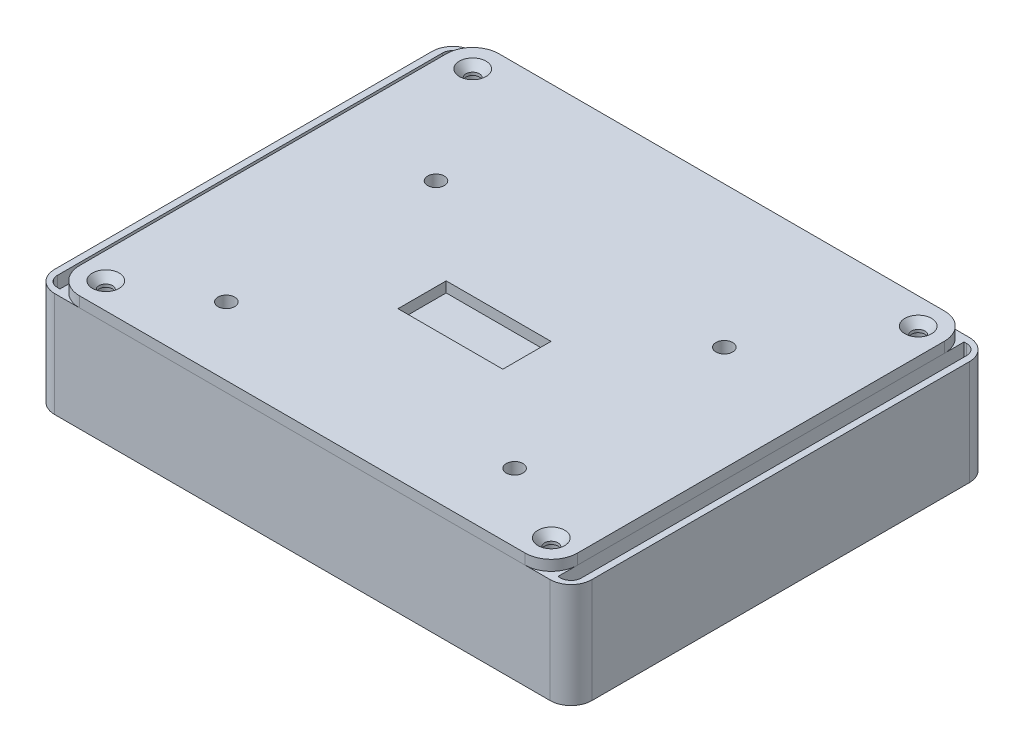
from build123d import *

# Parameters (mm, degrees)
BOSS_EXTRUDE2_DEPTH     = 25.4
SHELL2_T                = -1.2
BOSS_EXTRUDE3_DEPTH     = 24.2
BOSS_EXTRUDE8_DEPTH     = 24.2
SKETCH8_R               = 2.0193
CUT_EXTRUDE2_DEPTH      = 12.7
MIRROR2_COPY_1_DEPTH    = 24.2
MIRROR2_COPY_2_SKETCH_R = 2.0193
MIRROR2_COPY_2_DEPTH    = 12.7
CUT_EXTRUDE3_DEPTH      = 12.7
CUT_EXTRUDE4_DEPTH      = 2.2
BOSS_EXTRUDE4_DEPTH     = 2.54
SKETCH14_R              = 3.6193
BOSS_EXTRUDE6_DEPTH     = 0.889
SKETCH16_R              = 2.0193
SKETCH16_W              = 25.4
SKETCH16_H              = 11.674
CUT_EXTRUDE5_DEPTH      = 28.94
BOSS_EXTRUDE7_DEPTH     = 25.4
FILLET3_R               = 5.08
FILLET4_R               = 2.54
FILLET3_OF_MIRROR5_R    = 5.08
FILLET4_OF_MIRROR5_R    = 2.54
FILLET6_R               = 3.175


with BuildPart() as part:
    # Sketch5 → Boss-Extrude2 (new body)
    with BuildSketch(Plane(origin=(0, 0, 0), x_dir=(1, 0, 0), z_dir=(0, 1, 0))):
        with BuildLine():
            Line((-53.975, 50.8), (53.975, 50.8))
            ThreePointArc((53.975, 50.8), (58.465128061, 48.940128061), (60.325, 44.45))
            Line((60.325, 44.45), (60.325, -44.45))
            ThreePointArc((60.325, -44.45), (58.465128061, -48.940128061), (53.975, -50.8))
            Line((53.975, -50.8), (-53.975, -50.8))
            ThreePointArc((-53.975, -50.8), (-58.465128061, -48.940128061), (-60.325, -44.45))
            Line((-60.325, -44.45), (-60.325, 44.45))
            ThreePointArc((-60.325, 44.45), (-58.465128061, 48.940128061), (-53.975, 50.8))
        make_face()
    extrude(amount=BOSS_EXTRUDE2_DEPTH)

    # Shell2
    shell2_openings = [part.faces().sort_by_distance(p)[0] for p in [
        (0, 25.4, 0),
    ]]
    offset(amount=SHELL2_T, openings=shell2_openings, kind=Kind.INTERSECTION)

    # Sketch6 → Boss-Extrude3 (add)
    with BuildSketch(Plane(origin=(0, 1.2, 0), x_dir=(1, 0, 0), z_dir=(0, 1, 0))):
        with BuildLine():
            Line((-50.6857, 49.6), (-53.975, 49.6))
            ThreePointArc((-53.975, 49.6), (-57.616599923, 48.091599923), (-59.125, 44.45))
            Line((-59.125, 44.45), (-59.125, 41.1607))
            Line((-59.125, 41.1607), (-53.8607, 41.1607))
            ThreePointArc((-53.8607, 41.1607), (-51.61563597, 42.09063597), (-50.6857, 44.3357))
            Line((-50.6857, 44.3357), (-50.6857, 49.6))
        make_face()
    boss_extrude3 = extrude(amount=BOSS_EXTRUDE3_DEPTH)

    # Sketch20 → Boss-Extrude8 (add)
    with BuildSketch(Plane(origin=(0, 1.2, 0), x_dir=(1, 0, 0), z_dir=(0, 1, 0))):
        with BuildLine():
            Line((-3.2893, 49.6), (3.2893, 49.6))
            Line((3.2893, 49.6), (3.2893, 44.3357))
            ThreePointArc((3.2893, 44.3357), (2.35936403, 42.09063597), (0.1143, 41.1607))
            Line((0.1143, 41.1607), (-0.1143, 41.1607))
            ThreePointArc((-0.1143, 41.1607), (-2.35936403, 42.09063597), (-3.2893, 44.3357))
            Line((-3.2893, 44.3357), (-3.2893, 49.6))
        make_face()
    boss_extrude8 = extrude(amount=BOSS_EXTRUDE8_DEPTH)

    # Sketch8 → Cut-Extrude2 (cut)
    with BuildSketch(Plane(origin=(0, 25.4, 0), x_dir=(1, 0, 0), z_dir=(0, 1, 0))):
        with Locations((-53.975, 44.45)):
            Circle(SKETCH8_R)
        with Locations((0, 44.45)):
            Circle(SKETCH8_R)
    cut_extrude2 = extrude(amount=-CUT_EXTRUDE2_DEPTH, mode=Mode.SUBTRACT)

    # Mirror1: Boss-Extrude3, Cut-Extrude2 across plane
    add(boss_extrude3.mirror(Plane(origin=(0, 0, 0), x_dir=(0, 0, 1), z_dir=(1, 0, 0))))
    add(cut_extrude2.mirror(Plane(origin=(0, 0, 0), x_dir=(0, 0, 1), z_dir=(1, 0, 0))), mode=Mode.SUBTRACT)

    # Mirror2: Boss-Extrude8, Boss-Extrude3, Cut-Extrude2 across plane
    add(boss_extrude8.mirror(Plane.XY))
    add(boss_extrude3.mirror(Plane.XY))
    add(cut_extrude2.mirror(Plane.XY), mode=Mode.SUBTRACT)

    # Mirror2 copy 1 sketch → Mirror2 copy 1 (add)
    with BuildSketch(Plane(origin=(0, 1.2, 0), x_dir=(-1, 0, 0), z_dir=(0, 1, 0))):
        with BuildLine():
            Line((-50.6857, 49.6), (-53.975, 49.6))
            ThreePointArc((-53.975, 49.6), (-57.616599923, 48.091599923), (-59.125, 44.45))
            Line((-59.125, 44.45), (-59.125, 41.1607))
            Line((-59.125, 41.1607), (-53.8607, 41.1607))
            ThreePointArc((-53.8607, 41.1607), (-51.61563597, 42.09063597), (-50.6857, 44.3357))
            Line((-50.6857, 44.3357), (-50.6857, 49.6))
        make_face()
    extrude(amount=MIRROR2_COPY_1_DEPTH)

    # Mirror2 copy 2 sketch → Mirror2 copy 2 (cut)
    with BuildSketch(Plane(origin=(0, 25.4, 0), x_dir=(-1, 0, 0), z_dir=(0, 1, 0))):
        with Locations((-53.975, 44.45)):
            Circle(MIRROR2_COPY_2_SKETCH_R)
        with Locations((0, 44.45)):
            Circle(MIRROR2_COPY_2_SKETCH_R)
    extrude(amount=-MIRROR2_COPY_2_DEPTH, mode=Mode.SUBTRACT)

    # Sketch2 → Cut-Extrude3 (cut)
    with BuildSketch(Plane(origin=(0, 1.2, 0), x_dir=(1, 0, 0), z_dir=(0, 1, 0))):
        with BuildLine():
            Line((-29.868333333, -34.29), (-29.868333333, -41.91))
            ThreePointArc((-29.868333333, -41.91), (-29.607951262, -42.538617928), (-28.979333333, -42.799))
            Line((-28.979333333, -42.799), (-12.928466742, -42.799))
            Line((-12.928466742, -42.799), (-9.548333333, -39.418866591))
            Line((-9.548333333, -39.418866591), (-9.548333333, -36.781133409))
            Line((-9.548333333, -36.781133409), (-12.928466742, -33.401))
            Line((-12.928466742, -33.401), (-28.979333333, -33.401))
            ThreePointArc((-28.979333333, -33.401), (-29.607951262, -33.661382072), (-29.868333333, -34.29))
        make_face()
        with BuildLine():
            Line((9.548333333, -34.29), (9.548333333, -41.91))
            ThreePointArc((9.548333333, -41.91), (9.808715405, -42.538617928), (10.437333333, -42.799))
            Line((10.437333333, -42.799), (26.488199925, -42.799))
            Line((26.488199925, -42.799), (29.868333333, -39.418866591))
            Line((29.868333333, -39.418866591), (29.868333333, -36.781133409))
            Line((29.868333333, -36.781133409), (26.488199925, -33.401))
            Line((26.488199925, -33.401), (10.437333333, -33.401))
            ThreePointArc((10.437333333, -33.401), (9.808715405, -33.661382072), (9.548333333, -34.29))
        make_face()
    extrude(amount=-CUT_EXTRUDE3_DEPTH, mode=Mode.SUBTRACT)

    # Sketch9 → Cut-Extrude4 (cut, through all)
    with BuildSketch(Plane(origin=(0, 1.2, 0), x_dir=(1, 0, 0), z_dir=(0, 1, 0))):
        with BuildLine():
            Line((49.118316031, -38.6907), (49.118316031, -27.2607))
            ThreePointArc((49.118316031, -27.2607), (49.490290419, -26.362674388), (50.388316031, -25.9907))
            Line((50.388316031, -25.9907), (56.992316031, -25.9907))
            ThreePointArc((56.992316031, -25.9907), (57.890341643, -26.362674388), (58.262316031, -27.2607))
            Line((58.262316031, -27.2607), (58.262316031, -38.6907))
            ThreePointArc((58.262316031, -38.6907), (57.890341643, -39.588725612), (56.992316031, -39.9607))
            Line((56.992316031, -39.9607), (50.388316031, -39.9607))
            ThreePointArc((50.388316031, -39.9607), (49.490290419, -39.588725612), (49.118316031, -38.6907))
        make_face()
    extrude(amount=-CUT_EXTRUDE4_DEPTH, mode=Mode.SUBTRACT)

    # Sketch18 → Boss-Extrude7 (add)
    with BuildSketch(Plane.XZ):
        with BuildLine():
            Line((-53.975, -50.8), (-65.1, -50.8))
            Line((-65.1, -50.8), (-65.1, 50.8))
            Line((-65.1, 50.8), (-53.975, 50.8))
            ThreePointArc((-53.975, 50.8), (-58.465128061, 48.940128061), (-60.325, 44.45))
            Line((-60.325, 44.45), (-60.325, 49.2))
            Line((-60.325, 49.2), (-63.5, 49.2))
            Line((-63.5, 49.2), (-63.5, -49.2))
            Line((-63.5, -49.2), (-60.325, -49.2))
            Line((-60.325, -49.2), (-60.325, -44.45))
            ThreePointArc((-60.325, -44.45), (-58.465128061, -48.940128061), (-53.975, -50.8))
        make_face()
    boss_extrude7 = extrude(amount=-BOSS_EXTRUDE7_DEPTH)

    # Fillet3
    fillet3_edges = [part.edges().sort_by_distance(p)[0] for p in [
        (-65.1, 12.7, -50.8),
        (-65.1, 12.7, 50.8),
    ]]
    fillet(fillet3_edges, radius=FILLET3_R)

    # Fillet4
    fillet4_edges = [part.edges().sort_by_distance(p)[0] for p in [
        (-63.5, 12.7, 49.2),
        (-63.5, 12.7, -49.2),
    ]]
    fillet(fillet4_edges, radius=FILLET4_R)

    # Mirror5: Boss-Extrude7 across plane
    add(boss_extrude7.mirror(Plane(origin=(0, 0, 0), x_dir=(0, 0, 1), z_dir=(1, 0, 0))))

    # Fillet3 of Mirror5
    fillet3_of_mirror5_edges = [part.edges().sort_by_distance(p)[0] for p in [
        (65.1, 12.7, -50.8),
        (65.1, 12.7, 50.8),
    ]]
    fillet(fillet3_of_mirror5_edges, radius=FILLET3_OF_MIRROR5_R)

    # Fillet4 of Mirror5
    fillet4_of_mirror5_edges = [part.edges().sort_by_distance(p)[0] for p in [
        (63.5, 12.7, 49.2),
        (63.5, 12.7, -49.2),
    ]]
    fillet(fillet4_of_mirror5_edges, radius=FILLET4_OF_MIRROR5_R)

    # Fillet6
    fillet6_edges = [part.edges().sort_by_distance(p)[0] for p in [
        (-3.2893, 13.3, 49.6),
        (3.2893, 13.3, 49.6),
        (3.2893, 13.3, -49.6),
        (-3.2893, 13.3, -49.6),
    ]]
    fillet(fillet6_edges, radius=FILLET6_R)


with BuildPart() as body_2:
    # Sketch10 → Boss-Extrude4 (new body)
    with BuildSketch(Plane(origin=(0, 25.4, 0), x_dir=(1, 0, 0), z_dir=(0, 1, 0))):
        with BuildLine():
            Line((53.975, 50.8), (-53.975, 50.8))
            ThreePointArc((-53.975, 50.8), (-58.465128061, 48.940128061), (-60.325, 44.45))
            Line((-60.325, 44.45), (-60.325, -44.45))
            ThreePointArc((-60.325, -44.45), (-58.465128061, -48.940128061), (-53.975, -50.8))
            Line((-53.975, -50.8), (53.975, -50.8))
            ThreePointArc((53.975, -50.8), (58.465128061, -48.940128061), (60.325, -44.45))
            Line((60.325, -44.45), (60.325, 44.45))
            ThreePointArc((60.325, 44.45), (58.465128061, 48.940128061), (53.975, 50.8))
        make_face()
    extrude(amount=BOSS_EXTRUDE4_DEPTH)

    # Sketch12 → CSK for #4 Flat Head Machine Screw1 (revolve, cut)
    with BuildSketch(Plane(origin=(-53.975, 27.94, -44.45), x_dir=(0, 0, 1), z_dir=(1, 0, 0))):
        Polygon((0, 0), (0, 27.94), (1.63195, 27.94), (1.63195, 1.848124365), (3.2385, 0), align=None)
    csk_for_4_flat_head_machine_screw1 = revolve(axis=Axis((-53.975, 34.29, -44.45), (0, -1, 0)), mode=Mode.SUBTRACT)

    # Mirror3: CSK for #4 Flat Head Machine Screw1 across plane
    add(csk_for_4_flat_head_machine_screw1.mirror(Plane.XY), mode=Mode.SUBTRACT)

    # Mirror4: CSK for #4 Flat Head Machine Screw1 across plane
    add(csk_for_4_flat_head_machine_screw1.mirror(Plane(origin=(0, 0, 0), x_dir=(0, 0, 1), z_dir=(1, 0, 0))), mode=Mode.SUBTRACT)

    # Mirror4 copy 1 sketch → Mirror4 copy 1 (revolve, cut)
    with BuildSketch(Plane(origin=(53.975, 27.94, 44.45), x_dir=(0, 0, -1), z_dir=(-1, 0, 0))):
        Polygon((0, 0), (0, 27.94), (1.63195, 27.94), (1.63195, 1.848124365), (3.2385, 0), align=None)
    revolve(axis=Axis((53.975, 34.29, 44.45), (0, -1, 0)), mode=Mode.SUBTRACT)

    # Sketch14 → Boss-Extrude6 (add)
    with BuildSketch(Plane.XZ.offset(-25.4)):
        with Locations((-34.925, 34.29)):
            Circle(SKETCH14_R)
        with Locations((-34.925, -16.51)):
            Circle(SKETCH14_R)
        with Locations((34.925, -16.51)):
            Circle(SKETCH14_R)
        with Locations((34.925, 34.29)):
            Circle(SKETCH14_R)
    extrude(amount=BOSS_EXTRUDE6_DEPTH)

    # Sketch16 → Cut-Extrude5 (cut, through all)
    with BuildSketch(Plane(origin=(0, 27.94, 0), x_dir=(1, 0, 0), z_dir=(0, 1, 0))):
        with Locations((34.925, 16.51)):
            Circle(SKETCH16_R)
        with Locations((34.925, -34.29)):
            Circle(SKETCH16_R)
        with Locations((-34.925, -34.29)):
            Circle(SKETCH16_R)
        with Locations((-34.925, 16.51)):
            Circle(SKETCH16_R)
        with Locations((0, -9.085)):
            Rectangle(SKETCH16_W, SKETCH16_H)
    extrude(amount=-CUT_EXTRUDE5_DEPTH, mode=Mode.SUBTRACT)


solid = Compound([part.part, body_2.part])
